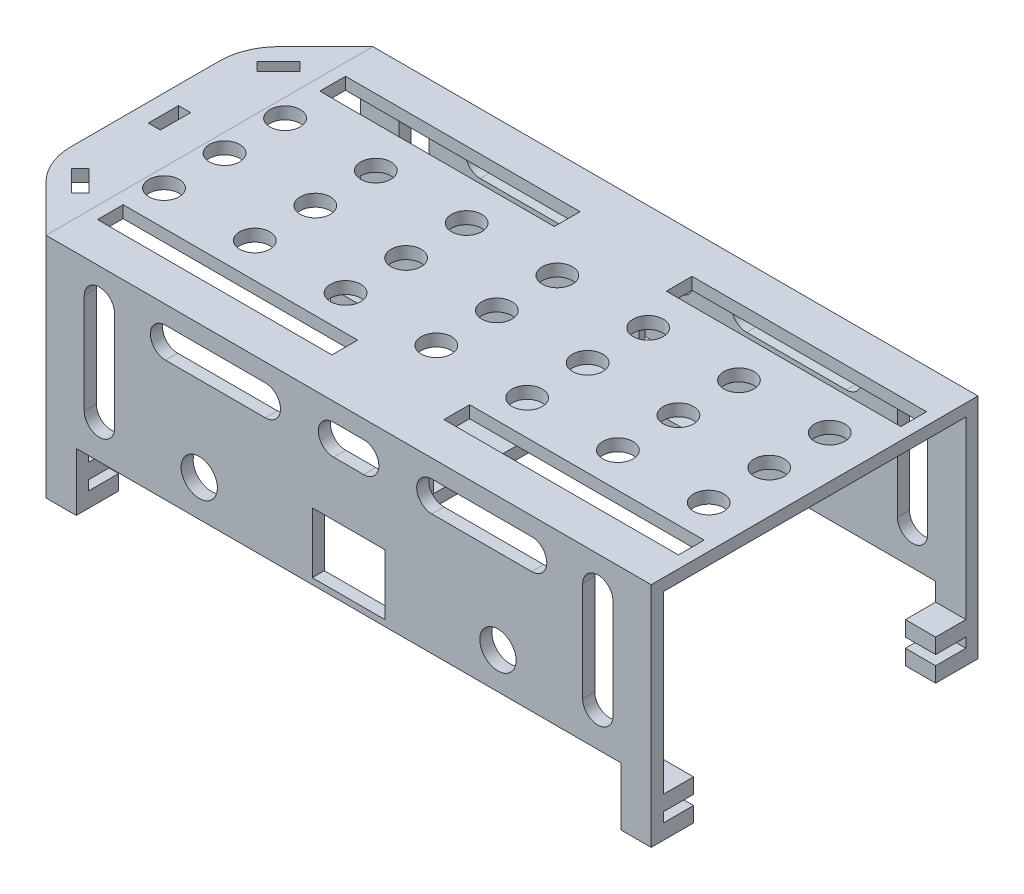
from build123d import *

# Parameters (mm, degrees)
SKETCH1_W                = 100
SKETCH1_H                = 28
SKETCH1_R                = 3
SKETCH1_W_2              = 12
SKETCH1_H_2              = 10
BOSS_EXTRUDE1_DEPTH      = 1
SKETCH4_W                = 100
SKETCH4_H                = 2
BOSS_EXTRUDE2_DEPTH      = 52
SKETCH5_W                = 100
SKETCH5_H                = 2
BOSS_EXTRUDE3_DEPTH      = 26
SKETCH6_W                = 12
SKETCH6_H                = 10
CUT_EXTRUDE1_DEPTH       = 26
SKETCH7_R                = 2
CUT_EXTRUDE2_DEPTH       = 26
SKETCH9_W                = 60.638660184
SKETCH9_H                = 41.98862088
CUT_EXTRUDE4_DEPTH       = 51
CUT_EXTRUDE4_DEPTH_BACK  = 51
BOSS_EXTRUDE12_DEPTH     = 2
FILLET1_R                = 10
CUT_EXTRUDE15_DEPTH      = 2
SKETCH52_R               = 2.5
CUT_EXTRUDE28_DEPTH      = 10
SKETCH64_W               = 2
SKETCH64_H               = 5
CUT_EXTRUDE30_DEPTH      = 2
CUT_EXTRUDE31_DEPTH      = 1
CUT_EXTRUDE31_DEPTH_BACK = 55
SKETCH65_W               = 38.75
SKETCH65_H               = 4.25
CUT_EXTRUDE32_DEPTH      = 27
CUT_EXTRUDE32_DEPTH_BACK = 3
SKETCH45_W               = 8
SKETCH45_H               = 36
BOSS_EXTRUDE13_DEPTH     = 15
SKETCH67_W               = 34
SKETCH67_H               = 13
CUT_EXTRUDE33_DEPTH      = 15
SKETCH68_R               = 2.5
CUT_EXTRUDE34_DEPTH      = 15
SKETCH69_R               = 3
CUT_EXTRUDE35_DEPTH      = 10
SKETCH71_W               = 5
SKETCH71_H               = 2
BOSS_EXTRUDE14_DEPTH     = 9.6
SKETCH72_W               = 5
SKETCH72_H               = 2.5
BOSS_EXTRUDE15_DEPTH     = 5
SKETCH73_W               = 5
SKETCH73_H               = 2.5
BOSS_EXTRUDE16_DEPTH     = 5


with BuildPart() as part:
    # Sketch1 → Boss-Extrude1 (new body, symmetric)
    with BuildSketch(Plane.XY):
        with Locations((0, 8)):
            Rectangle(SKETCH1_W, SKETCH1_H)
        with Locations((24.68, 0)):
            Circle(SKETCH1_R, mode=Mode.SUBTRACT)
        with Locations((-24.68, 0)):
            Circle(SKETCH1_R, mode=Mode.SUBTRACT)
        Rectangle(SKETCH1_W_2, SKETCH1_H_2, mode=Mode.SUBTRACT)
    extrude(amount=BOSS_EXTRUDE1_DEPTH, both=True)

    # Sketch4 → Boss-Extrude2 (add)
    with BuildSketch(Plane.XY.offset(1)):
        with Locations((0, 21)):
            Rectangle(SKETCH4_W, SKETCH4_H)
    extrude(amount=BOSS_EXTRUDE2_DEPTH)

    # Sketch5 → Boss-Extrude3 (add)
    with BuildSketch(Plane.XZ.offset(-20)):
        with Locations((0, 52)):
            Rectangle(SKETCH5_W, SKETCH5_H)
    extrude(amount=BOSS_EXTRUDE3_DEPTH)

    # Sketch6 → Cut-Extrude1 (cut)
    with BuildSketch(Plane(origin=(0, 0, 51), x_dir=(-1, 0, 0), z_dir=(0, 0, -1))):
        Rectangle(SKETCH6_W, SKETCH6_H)
    extrude(amount=-CUT_EXTRUDE1_DEPTH, mode=Mode.SUBTRACT)

    # Sketch7 → Cut-Extrude2 (cut)
    with BuildSketch(Plane(origin=(0, 0, 51), x_dir=(-1, 0, 0), z_dir=(0, 0, -1))):
        with Locations((-24.68, 0)):
            Circle(SKETCH7_R)
        with Locations((24.68, 0)):
            Circle(SKETCH7_R)
    extrude(amount=-CUT_EXTRUDE2_DEPTH, mode=Mode.SUBTRACT)


with BuildPart() as body_2:
    # Mirror6: mirrored copy
    add(part.part.mirror(Plane.XY))

    # Sketch52 → Cut-Extrude28 (cut)
    with BuildSketch(Plane(origin=(0, 22, 0), x_dir=(1, 0, 0), z_dir=(0, 1, 0))):
        with Locations((13, 35.5)):
            Circle(SKETCH52_R)
        with Locations((13, 25.5)):
            Circle(SKETCH52_R)
        with Locations((28, 25.5)):
            Circle(SKETCH52_R)
        with Locations((43, 25.5)):
            Circle(SKETCH52_R)
        with Locations((43, 15.5)):
            Circle(SKETCH52_R)
        with Locations((13, 15.5)):
            Circle(SKETCH52_R)
        with Locations((-32, 35.5)):
            Circle(SKETCH52_R)
        with Locations((-17, 25.5)):
            Circle(SKETCH52_R)
        with Locations((-17, 15.5)):
            Circle(SKETCH52_R)
        with Locations((43, 35.5)):
            Circle(SKETCH52_R)
        with Locations((28, 35.5)):
            Circle(SKETCH52_R)
        with Locations((28, 15.5)):
            Circle(SKETCH52_R)
        with Locations((-17, 35.5)):
            Circle(SKETCH52_R)
        with Locations((-47, 35.5)):
            Circle(SKETCH52_R)
        with Locations((-47, 25.5)):
            Circle(SKETCH52_R)
        with Locations((-32, 25.5)):
            Circle(SKETCH52_R)
        with Locations((-32, 15.5)):
            Circle(SKETCH52_R)
        with Locations((-47, 15.5)):
            Circle(SKETCH52_R)
    extrude(amount=-CUT_EXTRUDE28_DEPTH, mode=Mode.SUBTRACT)

    # Sketch51 → Cut-Extrude31 (cut, two sides)
    with BuildSketch(Plane(origin=(0, 0, -53), x_dir=(-1, 0, 0), z_dir=(0, 0, -1))) as cut_extrude31_sk:
        with BuildLine():
            Line((-38.68, 16.5), (-38.68, 0))
            ThreePointArc((-38.68, 0), (-41.18, -2.5), (-43.68, 0))
            Line((-43.68, 0), (-43.68, 16.5))
            ThreePointArc((-43.68, 16.5), (-41.18, 19), (-38.68, 16.5))
        make_face()
        with BuildLine():
            Line((-30.25, 19), (-13.75, 19))
            ThreePointArc((-13.75, 19), (-11.25, 16.5), (-13.75, 14))
            Line((-13.75, 14), (-30.25, 14))
            ThreePointArc((-30.25, 14), (-32.75, 16.5), (-30.25, 19))
        make_face()
        with BuildLine():
            Line((-2.5, 19), (2.5, 19))
            ThreePointArc((2.5, 19), (5, 16.5), (2.5, 14))
            Line((2.5, 14), (-2.5, 14))
            ThreePointArc((-2.5, 14), (-5, 16.5), (-2.5, 19))
        make_face()
        with BuildLine():
            Line((13.75, 19), (30.25, 19))
            ThreePointArc((30.25, 19), (32.75, 16.5), (30.25, 14))
            Line((30.25, 14), (13.75, 14))
            ThreePointArc((13.75, 14), (11.25, 16.5), (13.75, 19))
        make_face()
        with BuildLine():
            Line((43.68, 16.5), (43.68, 0))
            ThreePointArc((43.68, 0), (41.18, -2.5), (38.68, 0))
            Line((38.68, 0), (38.68, 16.5))
            ThreePointArc((38.68, 16.5), (41.18, 19), (43.68, 16.5))
        make_face()
    extrude(amount=CUT_EXTRUDE31_DEPTH, mode=Mode.SUBTRACT)
    extrude(cut_extrude31_sk.sketch, amount=-CUT_EXTRUDE31_DEPTH_BACK, mode=Mode.SUBTRACT)

    # Sketch65 → Cut-Extrude32 (cut, two sides)
    with BuildSketch(Plane.XZ.offset(-20)) as cut_extrude32_sk:
        with Locations((-28.625, -7.625)):
            Rectangle(SKETCH65_W, SKETCH65_H)
        with Locations((-28.625, -44.375)):
            Rectangle(SKETCH65_W, SKETCH65_H)
        with Locations((28.625, -44.375)):
            Rectangle(SKETCH65_W, SKETCH65_H)
        with Locations((28.625, -7.625)):
            Rectangle(SKETCH65_W, SKETCH65_H)
    extrude(amount=CUT_EXTRUDE32_DEPTH, mode=Mode.SUBTRACT)
    extrude(cut_extrude32_sk.sketch, amount=-CUT_EXTRUDE32_DEPTH_BACK, mode=Mode.SUBTRACT)

    # Sketch45 → Boss-Extrude13 (add)
    with BuildSketch(Plane.XZ.offset(-20)):
        with Locations((0, -26)):
            Rectangle(SKETCH45_W, SKETCH45_H)
    extrude(amount=BOSS_EXTRUDE13_DEPTH)

    # Sketch67 → Cut-Extrude33 (cut)
    with BuildSketch(Plane(origin=(4, 0, 0), x_dir=(0, 0, -1), z_dir=(1, 0, 0))):
        with Locations((26, 13.5)):
            Rectangle(SKETCH67_W, SKETCH67_H)
    extrude(amount=-CUT_EXTRUDE33_DEPTH, mode=Mode.SUBTRACT)

    # Sketch68 → Cut-Extrude34 (cut)
    with BuildSketch(Plane.XZ.offset(-20)):
        with Locations((-2, -15.5)):
            Circle(SKETCH68_R)
        with Locations((-2, -25.5)):
            Circle(SKETCH68_R)
        with Locations((-2, -35.5)):
            Circle(SKETCH68_R)
    extrude(amount=-CUT_EXTRUDE34_DEPTH, mode=Mode.SUBTRACT)

    # Sketch69 → Cut-Extrude35 (cut)
    with BuildSketch(Plane(origin=(0, 0, -53), x_dir=(-1, 0, 0), z_dir=(0, 0, -1))):
        with Locations((24.68, 0)):
            Circle(SKETCH69_R)
        with Locations((-24.68, 0)):
            Circle(SKETCH69_R)
    extrude(amount=-CUT_EXTRUDE35_DEPTH, mode=Mode.SUBTRACT)


with BuildPart() as part_1:
    add(part.part)

    # Sketch9 → Cut-Extrude4 (cut, two sides)
    with BuildSketch(Plane(origin=(0, 0, 0), x_dir=(0, 0, -1), z_dir=(1, 0, 0))) as cut_extrude4_sk:
        with Locations((-31.319330092, 14.99431044)):
            Rectangle(SKETCH9_W, SKETCH9_H)
    extrude(amount=CUT_EXTRUDE4_DEPTH, mode=Mode.SUBTRACT)
    extrude(cut_extrude4_sk.sketch, amount=-CUT_EXTRUDE4_DEPTH_BACK, mode=Mode.SUBTRACT)

    # Sketch50 → Cut-Extrude15 (cut)
    with BuildSketch(Plane.XY.offset(1)):
        with BuildLine():
            Line((-43.68, 0), (-43.68, 16.5))
            ThreePointArc((-43.68, 16.5), (-41.18, 19), (-38.68, 16.5))
            Line((-38.68, 16.5), (-38.68, 0))
            ThreePointArc((-38.68, 0), (-41.18, -2.5), (-43.68, 0))
        make_face()
        with BuildLine():
            Line((-30.25, 19), (-13.75, 19))
            ThreePointArc((-13.75, 19), (-11.25, 16.5), (-13.75, 14))
            Line((-13.75, 14), (-30.25, 14))
            ThreePointArc((-30.25, 14), (-32.75, 16.5), (-30.25, 19))
        make_face()
        with BuildLine():
            Line((38.68, 0), (38.68, 16.5))
            ThreePointArc((38.68, 16.5), (41.18, 19), (43.68, 16.5))
            Line((43.68, 16.5), (43.68, 0))
            ThreePointArc((43.68, 0), (41.18, -2.5), (38.68, 0))
        make_face()
        with BuildLine():
            Line((13.75, 19), (30.25, 19))
            ThreePointArc((30.25, 19), (32.75, 16.5), (30.25, 14))
            Line((30.25, 14), (13.75, 14))
            ThreePointArc((13.75, 14), (11.25, 16.5), (13.75, 19))
        make_face()
        with BuildLine():
            Line((-2.5, 19), (2.5, 19))
            ThreePointArc((2.5, 19), (5, 16.5), (2.5, 14))
            Line((2.5, 14), (-2.5, 14))
            ThreePointArc((-2.5, 14), (-5, 16.5), (-2.5, 19))
        make_face()
    extrude(amount=-CUT_EXTRUDE15_DEPTH, mode=Mode.SUBTRACT)

    add(body_2.part)  # Boss-Extrude14 merges body 2
    # Sketch71 → Boss-Extrude14 (add)
    with BuildSketch(Plane.XZ.offset(6)):
        with Locations((-47.5, -52)):
            Rectangle(SKETCH71_W, SKETCH71_H)
        with Locations((47.5, -52)):
            Rectangle(SKETCH71_W, SKETCH71_H)
        with Locations((47.5, 0)):
            Rectangle(SKETCH71_W, SKETCH71_H)
        with Locations((-47.5, 0)):
            Rectangle(SKETCH71_W, SKETCH71_H)
    extrude(amount=BOSS_EXTRUDE14_DEPTH)

    # Sketch72 → Boss-Extrude15 (add)
    with BuildSketch(Plane.XY.offset(-51)):
        with Locations((47.5, -14.35)):
            Rectangle(SKETCH72_W, SKETCH72_H)
        with Locations((47.5, -10.25)):
            Rectangle(SKETCH72_W, SKETCH72_H)
        with Locations((-47.5, -14.35)):
            Rectangle(SKETCH72_W, SKETCH72_H)
        with Locations((-47.5, -10.25)):
            Rectangle(SKETCH72_W, SKETCH72_H)
    extrude(amount=BOSS_EXTRUDE15_DEPTH)

    # Sketch73 → Boss-Extrude16 (add)
    with BuildSketch(Plane(origin=(0, 0, -1), x_dir=(-1, 0, 0), z_dir=(0, 0, -1))):
        with Locations((47.5, -14.35)):
            Rectangle(SKETCH73_W, SKETCH73_H)
        with Locations((47.5, -10.25)):
            Rectangle(SKETCH73_W, SKETCH73_H)
        with Locations((-47.5, -14.35)):
            Rectangle(SKETCH73_W, SKETCH73_H)
        with Locations((-47.5, -10.25)):
            Rectangle(SKETCH73_W, SKETCH73_H)
    extrude(amount=BOSS_EXTRUDE16_DEPTH)


with BuildPart() as body_3:
    # Sketch19 → Boss-Extrude12 (new body)
    with BuildSketch(Plane.XZ.offset(-20)):
        Polygon((-50, -53), (-50, 1), (-60.606601718, -9.606601718), (-60.606601718, -42.393398282), align=None)
    extrude(amount=-BOSS_EXTRUDE12_DEPTH)

    # Fillet1
    fillet1_edges = [body_3.edges().sort_by_distance(p)[0] for p in [
        (-60.606601718, 21, -42.393398282),
        (-60.606601718, 21, -9.606601718),
    ]]
    fillet(fillet1_edges, radius=FILLET1_R)

    # Sketch64 → Cut-Extrude30 (cut)
    with BuildSketch(Plane.XZ.offset(-20)):
        with Locations((-56.606601718, -26)):
            Rectangle(SKETCH64_W, SKETCH64_H)
        Polygon((-56.035533906, -12.106601718), (-52.5, -8.571067812), (-53.914213562, -7.156854249), (-57.449747468, -10.692388155), align=None)
        Polygon((-52.5, -43.428932188), (-53.914213562, -44.843145751), (-57.449747468, -41.307611845), (-56.035533906, -39.893398282), align=None)
    extrude(amount=-CUT_EXTRUDE30_DEPTH, mode=Mode.SUBTRACT)


solid = Compound([part_1.part, body_3.part])
